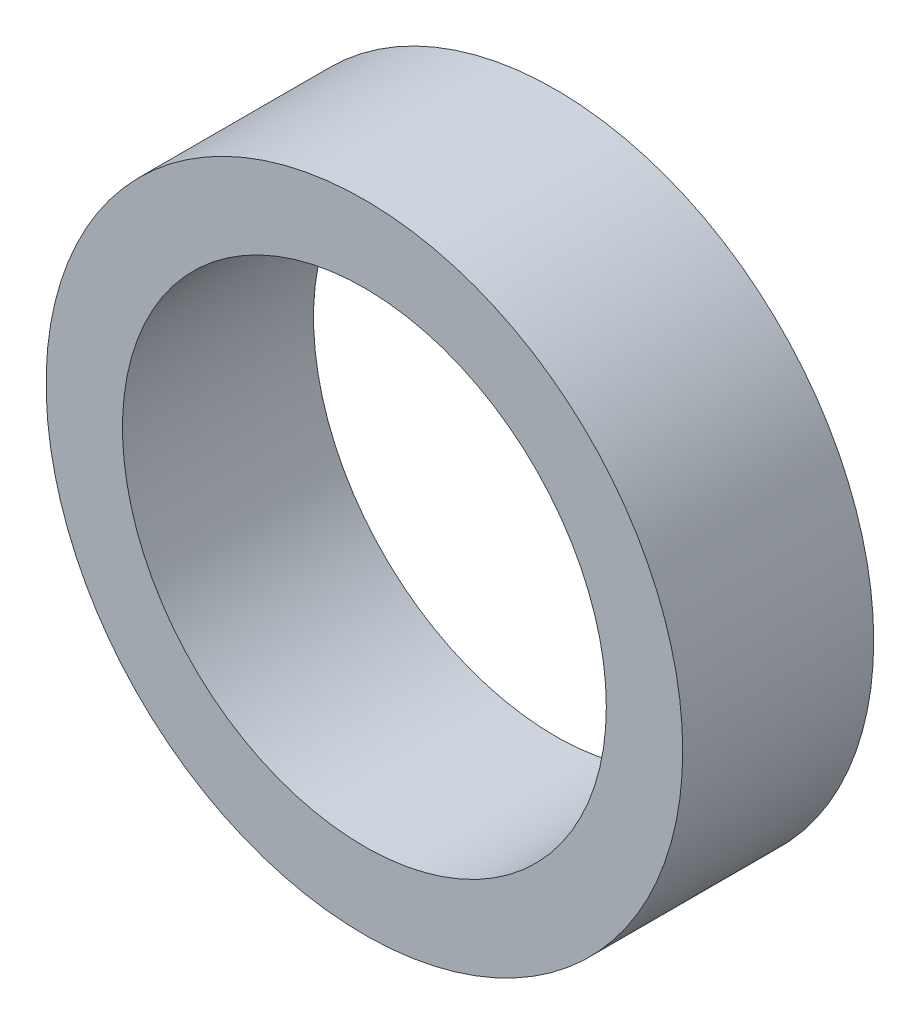
from build123d import *

# Parameters (mm, degrees)
ESBO_O1_R                = 10
ESBO_O1_R_2              = 7.6
RESSALTO_EXTRUS_O1_DEPTH = 6


with BuildPart() as part:
    # Esboço1 → Ressalto-extrusão1 (new body)
    with BuildSketch(Plane.XY):
        Circle(ESBO_O1_R)
        Circle(ESBO_O1_R_2, mode=Mode.SUBTRACT)
    extrude(amount=RESSALTO_EXTRUS_O1_DEPTH)


solid = part.part
